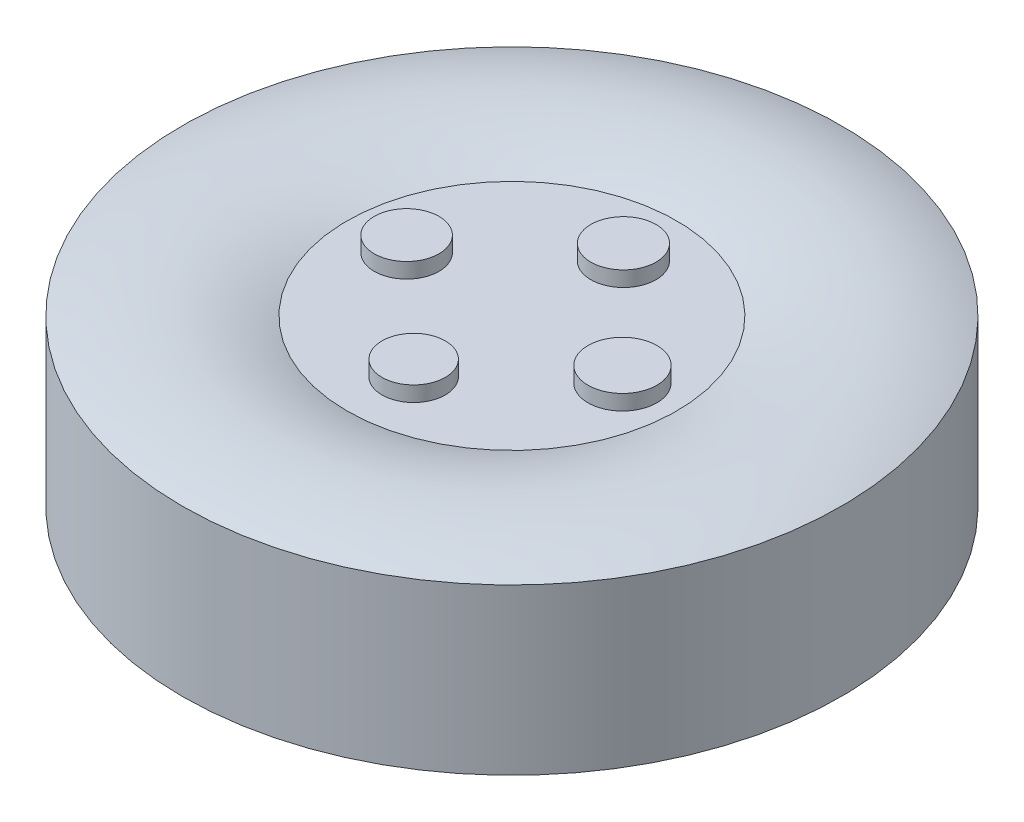
from build123d import *

# Parameters (mm, degrees)
SKETCH5_R                = 0.098984302
SKETCH5_R_2              = 0.104475871
SKETCH5_R_3              = 0.095992018
SKETCH5_R_4              = 0.098284334
BOSS_EXTRUDE2_DEPTH      = 0.046294
BOSS_EXTRUDE2_DEPTH_BACK = 0.546165


with BuildPart() as part:
    # Sketch4 → Revolve1 (revolve)
    with BuildSketch(Plane.XY):
        with BuildLine():
            Line((-77.862668244, 20.387242407), (-77.362668244, 20.387242407))
            ThreePointArc((-77.362668244, 20.387242407), (-77.112668244, 20.433536252), (-76.862668244, 20.387242407))
            Line((-76.862668244, 20.387242407), (-76.862668244, 19.887242407))
            ThreePointArc((-76.862668244, 19.887242407), (-77.112668244, 19.841077248), (-77.362668244, 19.887242407))
            Line((-77.362668244, 19.887242407), (-77.862668244, 19.887242407))
            Line((-77.862668244, 19.887242407), (-77.862668244, 20.387242407))
        make_face()
    revolve(axis=Axis((-77.862668244, 20.387242407, 0), (0, -1, 0)))

    # Sketch5 → Boss-Extrude2 (add, two sides)
    with BuildSketch(Plane(origin=(0, 20.387242407, 0), x_dir=(1, 0, 0), z_dir=(0, 1, 0))) as boss_extrude2_sk:
        with Locations((-77.838023518, 0.313742014)):
            Circle(SKETCH5_R)
        with Locations((-77.518777636, -0.008508906)):
            Circle(SKETCH5_R_2)
        with Locations((-77.85187015, -0.308843625)):
            Circle(SKETCH5_R_3)
        with Locations((-78.188509353, 0.006386281)):
            Circle(SKETCH5_R_4)
    extrude(amount=BOSS_EXTRUDE2_DEPTH)
    extrude(boss_extrude2_sk.sketch, amount=-BOSS_EXTRUDE2_DEPTH_BACK)


solid = part.part
